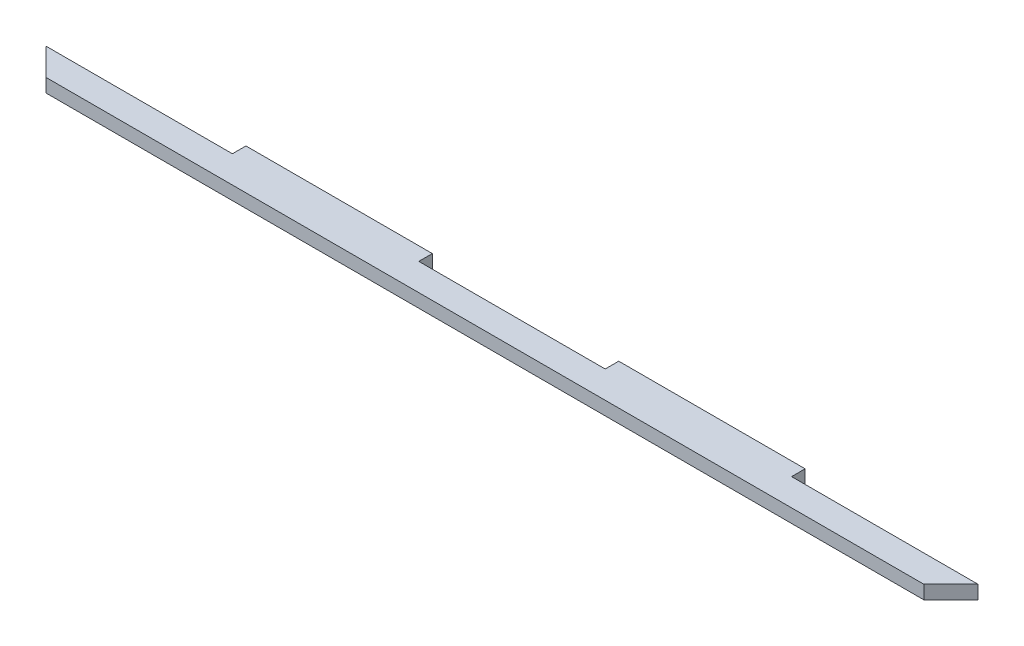
from build123d import *

# Parameters (mm, degrees)
BOSS_EXTRUDE1_DEPTH = 3


with BuildPart() as part:
    # Sketch1 → Boss-Extrude1 (new body)
    with BuildSketch(Plane(origin=(0, 0, 0), x_dir=(1, 0, 0), z_dir=(0, 1, 0))):
        Polygon((-61.95, 4.5), (-20.65, 4.5), (-20.65, 1.5), (20.65, 1.5), (20.65, 4.5), (61.95, 4.5), (61.95, 1.5), (103.25, 1.5), (97.25, -4.5), (-97.25, -4.5), (-103.25, 1.5), (-61.95, 1.5), align=None)
    extrude(amount=BOSS_EXTRUDE1_DEPTH)


solid = part.part
